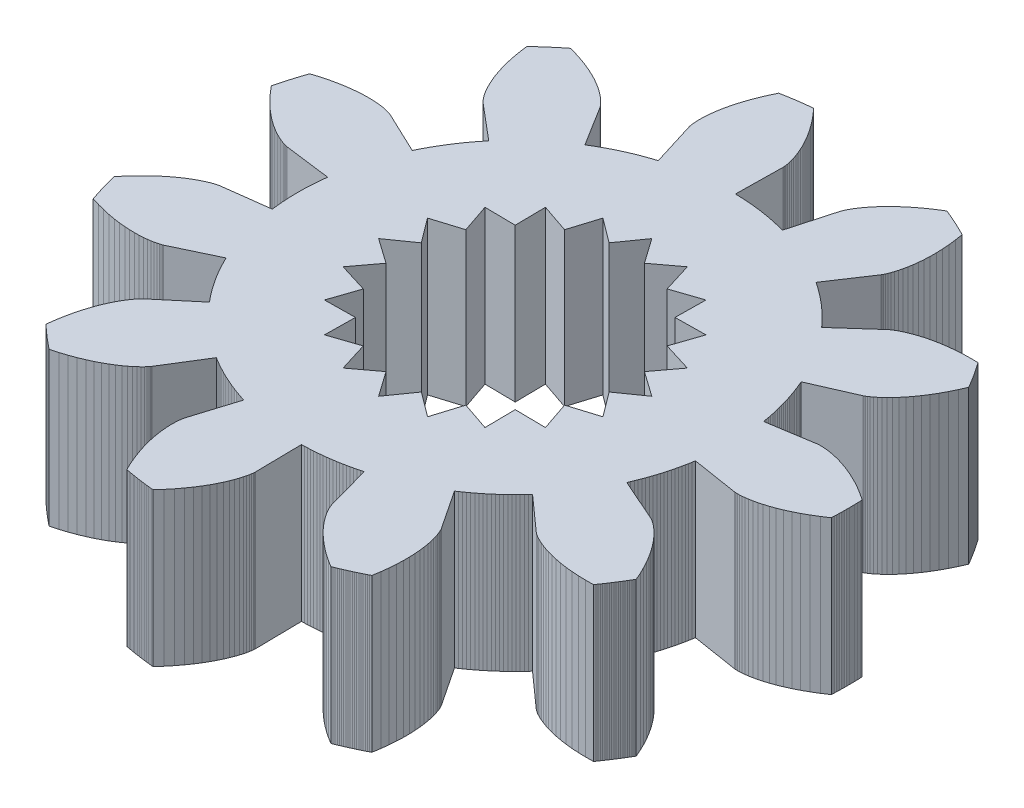
from build123d import *

# Parameters (mm, degrees)
BOSS_EXTRUDE1_DEPTH = 3
CUT_EXTRUDE1_DEPTH  = 4


with BuildPart() as part:
    # Sketch2 → Boss-Extrude1 (new body)
    with BuildSketch(Plane(origin=(0, 0, 0), x_dir=(1, 0, 0), z_dir=(0, 1, 0))):
        Polygon((4.197259488, -0.667467448), (5.104173112, -0.81168901), (5.108301421, -0.812232692), (5.120736405, -0.813420847), (5.14152309, -0.814586326), (5.170666294, -0.815059939), (5.208130563, -0.814172611), (5.253840203, -0.811257536), (5.307679433, -0.805652332), (5.369492635, -0.796701175), (5.439084718, -0.783756935), (5.516221584, -0.76618328), (5.600630705, -0.74335676), (5.692001799, -0.714668865), (5.789987608, -0.679528041), (5.894204785, -0.637361675), (6.004234873, -0.587618026), (6.119625381, -0.529768117), (6.239890958, -0.463307569), (6.364514658, -0.38775837), (6.492949292, -0.302670597), (6.494355324, -0.270830071), (6.495605215, -0.238983033), (6.496698936, -0.207130249), (6.497636459, -0.175272485), (6.498417763, -0.143410507), (6.499042829, -0.111545081), (6.499511642, -0.079676974), (6.49982419, -0.04780695), (6.499980465, -0.015935778), (6.499980465, 0.015935778), (6.49982419, 0.04780695), (6.499511642, 0.079676974), (6.499042829, 0.111545081), (6.498417763, 0.143410507), (6.497636459, 0.175272485), (6.496698936, 0.207130249), (6.495605215, 0.238983033), (6.494355324, 0.270830071), (6.492949292, 0.302670597), (6.364514658, 0.38775837), (6.239890958, 0.463307569), (6.119625381, 0.529768117), (6.004234873, 0.587618026), (5.894204785, 0.637361675), (5.789987608, 0.679528041), (5.692001799, 0.714668865), (5.600630705, 0.74335676), (5.516221584, 0.76618328), (5.439084718, 0.783756935), (5.369492635, 0.796701175), (5.307679433, 0.805652332), (5.253840203, 0.811257536), (5.208130563, 0.814172611), (5.170666294, 0.815059939), (5.14152309, 0.814586326), (5.120736405, 0.813420847), (5.108301421, 0.812232692), (5.104173112, 0.81168901), (4.197259488, 0.667467448), (4.187893514, 0.723911537), (4.177768525, 0.780224425), (4.166886354, 0.836395905), (4.155248975, 0.892415795), (4.142858497, 0.948273944), (4.129717165, 1.003960227), (4.115827361, 1.059464552), (4.101191602, 1.114776859), (4.085812541, 1.169887123), (4.069692965, 1.224785357), (4.052835796, 1.279461609), (4.035244089, 1.333905971), (4.016921033, 1.388108576), (3.997869947, 1.442059599), (3.978094286, 1.495749262), (3.957597632, 1.549167835), (3.936383702, 1.602305636), (3.914456339, 1.655153035), (3.891819519, 1.707700452), (4.732735872, 2.076688076), (4.736502764, 2.078462635), (4.747606104, 2.084185955), (4.765723081, 2.094443622), (4.790495959, 2.109801199), (4.821533181, 2.13080238), (4.858410569, 2.157967194), (4.900672609, 2.191790277), (4.947833823, 2.232739209), (4.999380224, 2.281252917), (5.05477085, 2.337740156), (5.113439373, 2.402578062), (5.174795781, 2.476110798), (5.238228126, 2.558648268), (5.303104336, 2.650464933), (5.368774089, 2.75179871), (5.434570739, 2.862849968), (5.499813295, 2.98378062), (5.563808443, 3.114713309), (5.62585261, 3.255730704), (5.60982115, 3.283276817), (5.593654817, 3.310743993), (5.577353998, 3.33813157), (5.560919086, 3.36543889), (5.544350475, 3.392665296), (5.527648564, 3.419810134), (5.510813754, 3.446872751), (5.493846451, 3.473852497), (5.476747062, 3.500748723), (5.459515998, 3.527560782), (5.442153673, 3.554288029), (5.424660506, 3.580929823), (5.407036916, 3.607485522), (5.389283327, 3.633954487), (5.371400167, 3.660336084), (5.353387864, 3.686629677), (5.335246853, 3.712834634), (5.316977569, 3.738950325), (5.298580451, 3.764976122), (5.144532438, 3.767119506), (4.99884733, 3.763298877), (4.861742203, 3.754188569), (4.733393509, 3.74047019), (4.613936862, 3.722830454), (4.503466934, 3.701958999), (4.402037463, 3.678546213), (4.309661361, 3.653281063), (4.226310941, 3.626848937), (4.151918244, 3.599929498), (4.086375474, 3.573194565), (4.029535539, 3.547306018), (3.981212694, 3.522913731), (3.941183289, 3.50065355), (3.909186616, 3.481145305), (3.884925846, 3.464990871), (3.86806908, 3.452772278), (3.858250471, 3.445049877), (3.855071452, 3.442360571), (3.170099226, 2.830719149), (3.131704089, 2.873139311), (3.09274136, 2.915038744), (3.053218101, 2.956409855), (3.013141475, 2.997245143), (2.972518746, 3.03753721), (2.931357277, 3.077278752), (2.889664526, 3.116462566), (2.847448051, 3.155081551), (2.804715504, 3.193128708), (2.761474628, 3.23059714), (2.717733261, 3.267480057), (2.673499331, 3.303770774), (2.628780855, 3.339462714), (2.583585936, 3.374549408), (2.537922768, 3.409024498), (2.491799625, 3.442881733), (2.445224867, 3.47611498), (2.398206935, 3.508718213), (2.350754351, 3.540685524), (2.858688433, 4.305731371), (2.860897945, 4.30926076), (2.867144409, 4.320078442), (2.876839667, 4.338502518), (2.889377004, 4.364815363), (2.904133082, 4.39926267), (2.920469908, 4.442052587), (2.937736859, 4.493354959), (2.955272732, 4.55330067), (2.972407833, 4.621981087), (2.988466086, 4.699447609), (3.00276717, 4.785711326), (3.014628667, 4.880742778), (3.023368225, 4.98447183), (3.028305729, 5.096787651), (3.028765465, 5.217538798), (3.024078287, 5.346533417), (3.013583771, 5.483539543), (2.996632359, 5.628285519), (2.972587474, 5.78046051), (2.944208399, 5.794966514), (2.915758538, 5.809333193), (2.887238574, 5.823560201), (2.858649194, 5.837647196), (2.829991085, 5.851593839), (2.801264936, 5.865399795), (2.772471438, 5.879064732), (2.743611282, 5.892588322), (2.714685163, 5.905970239), (2.685693776, 5.919210162), (2.656637818, 5.932307772), (2.627517989, 5.945262754), (2.598334987, 5.958074798), (2.569089514, 5.970743594), (2.539782274, 5.983268839), (2.510413971, 5.995650231), (2.480985312, 6.007887472), (2.451497004, 6.019980269), (2.421949755, 6.03192833), (2.291197519, 5.950446816), (2.170704995, 5.868469383), (2.060290228, 5.786680675), (1.959733151, 5.705749498), (1.868776585, 5.626326868), (1.787127329, 5.549044131), (1.714457336, 5.474511129), (1.650404984, 5.403314442), (1.594576436, 5.336015683), (1.546547064, 5.273149882), (1.505862973, 5.215223928), (1.472042582, 5.162715107), (1.444578285, 5.116069707), (1.422938169, 5.075701721), (1.406567807, 5.041991634), (1.394892096, 5.015285297), (1.387317152, 4.995892906), (1.383232257, 4.984088069), (1.382011846, 4.980106973), (1.136454858, 4.095237521), (1.081220742, 4.110165654), (1.025790665, 4.124348859), (0.970174673, 4.137784565), (0.914382847, 4.150470336), (0.858425296, 4.162403874), (0.802312165, 4.173583016), (0.746053622, 4.184005735), (0.689659864, 4.193670143), (0.633141111, 4.202574489), (0.576507608, 4.210717157), (0.519769618, 4.218096673), (0.462937425, 4.224711699), (0.406021329, 4.230561036), (0.349031646, 4.235643624), (0.291978703, 4.239958542), (0.234872843, 4.243505007), (0.177724414, 4.246282378), (0.120543774, 4.24829015), (0.063341286, 4.24952796), (0.077027616, 5.167735379), (0.076978243, 5.171899042), (0.076384623, 5.184376549), (0.074579985, 5.20511752), (0.070901266, 5.23403149), (0.064691249, 5.270988146), (0.055300686, 5.31581767), (0.042090413, 5.36831119), (0.02443343, 5.428221341), (0.001716958, 5.495262919), (-0.026655544, 5.569113652), (-0.061262393, 5.649415057), (-0.102661749, 5.735773411), (-0.151389724, 5.827760806), (-0.207958549, 5.924916303), (-0.272854793, 6.026747184), (-0.346537655, 6.132730282), (-0.429437307, 6.242313407), (-0.521953325, 6.354916845), (-0.624453181, 6.469934947), (-0.656169717, 6.466795288), (-0.687870476, 6.463500152), (-0.719554697, 6.460049616), (-0.751221618, 6.456443764), (-0.782870478, 6.452682684), (-0.814500516, 6.448766464), (-0.846110971, 6.4446952), (-0.877701084, 6.44046899), (-0.909270094, 6.436087934), (-0.940817243, 6.431552139), (-0.972341773, 6.426861713), (-1.003842925, 6.422016769), (-1.035319942, 6.417017424), (-1.066772068, 6.411863797), (-1.098198546, 6.406556014), (-1.12959862, 6.4010942), (-1.160971536, 6.395478488), (-1.192316539, 6.389709013), (-1.223632876, 6.383785913), (-1.289576423, 6.244549306), (-1.346620838, 6.110442324), (-1.395289338, 5.981942554), (-1.436128636, 5.859493655), (-1.469707053, 5.743504256), (-1.496612576, 5.634346959), (-1.517450882, 5.532357443), (-1.532843313, 5.437833663), (-1.543424821, 5.351035152), (-1.549841881, 5.272182436), (-1.552750382, 5.201456543), (-1.552813493, 5.138998628), (-1.550699523, 5.0849097), (-1.547079766, 5.03925046), (-1.542626341, 5.002041244), (-1.538010039, 4.973262077), (-1.533898169, 4.952852836), (-1.530952425, 4.940713514), (-1.529826757, 4.936704599), (-1.258005897, 4.059546916), (-1.31254255, 4.042243443), (-1.366841318, 4.024207352), (-1.420892358, 4.005441912), (-1.474685875, 3.985950523), (-1.52821212, 3.965736718), (-1.58146139, 3.944804161), (-1.634424036, 3.923156646), (-1.687090458, 3.900798096), (-1.73945111, 3.877732564), (-1.791496504, 3.853964229), (-1.843217206, 3.8294974), (-1.894603842, 3.80433651), (-1.945647099, 3.778486121), (-1.996337726, 3.751950917), (-2.046666536, 3.724735707), (-2.096624407, 3.696845425), (-2.146202285, 3.668285124), (-2.195391184, 3.639059982), (-2.244182189, 3.609175294), (-2.729088926, 4.389019917), (-2.731381507, 4.392495921), (-2.738626742, 4.402671732), (-2.751358315, 4.419144486), (-2.770085123, 4.441479601), (-2.795289599, 4.469212129), (-2.827426113, 4.501848203), (-2.866919442, 4.538866549), (-2.914163314, 4.579720089), (-2.96951904, 4.623837602), (-3.033314228, 4.670625459), (-3.105841579, 4.719469425), (-3.187357785, 4.769736514), (-3.278082506, 4.820776902), (-3.378197457, 4.871925892), (-3.487845583, 4.922505921), (-3.607130339, 4.971828615), (-3.736115075, 5.01919687), (-3.874822517, 5.063906975), (-4.023234364, 5.105250753), (-4.048218583, 5.085462251), (-4.073105473, 5.065551481), (-4.097894436, 5.045518922), (-4.122584875, 5.025365056), (-4.147176196, 5.005090368), (-4.171667809, 4.984695346), (-4.196059125, 4.964180478), (-4.220349557, 4.943546259), (-4.244538521, 4.922793185), (-4.268625436, 4.901921755), (-4.292609722, 4.88093247), (-4.316490803, 4.859825835), (-4.340268105, 4.838602358), (-4.363941056, 4.817262549), (-4.387509086, 4.79580692), (-4.41097163, 4.774235989), (-4.434328124, 4.752550272), (-4.457578005, 4.730750293), (-4.480720714, 4.708836574), (-4.460918963, 4.556051513), (-4.43640407, 4.412393001), (-4.407874398, 4.277979939), (-4.376029729, 4.152889978), (-4.341569086, 4.037159623), (-4.305188562, 3.930784438), (-4.267579166, 3.833719359), (-4.229424689, 3.745879118), (-4.191399603, 3.667138769), (-4.15416698, 3.597334318), (-4.118376462, 3.536263457), (-4.084662256, 3.483686395), (-4.053641189, 3.439326791), (-4.025910807, 3.402872783), (-4.002047526, 3.373978101), (-3.982604854, 3.352263287), (-3.96811166, 3.337316986), (-3.959070529, 3.328697328), (-3.955956174, 3.325933396), (-3.253058668, 2.734978849), (-3.289582857, 2.6909375), (-3.32551084, 2.646408445), (-3.360836105, 2.601399753), (-3.395552251, 2.555919582), (-3.429652986, 2.509976175), (-3.463132128, 2.463577858), (-3.495983611, 2.416733042), (-3.528201479, 2.369450215), (-3.559779895, 2.321737948), (-3.590713134, 2.273604889), (-3.620995591, 2.225059759), (-3.650621776, 2.176111359), (-3.679586321, 2.12676856), (-3.707883976, 2.077040303), (-3.735509612, 2.026935603), (-3.762458222, 1.97646354), (-3.788724923, 1.925633262), (-3.814304953, 1.874453981), (-3.839193676, 1.822934973), (-4.668739016, 2.216821643), (-4.672546928, 2.218506381), (-4.684143466, 2.223149748), (-4.70375979, 2.230124303), (-4.731589058, 2.23878932), (-4.767785749, 2.248492839), (-4.812465099, 2.258573739), (-4.865702631, 2.268363849), (-4.927533796, 2.277190068), (-4.997953724, 2.284376516), (-5.076917076, 2.289246684), (-5.164338009, 2.291125597), (-5.260090245, 2.289341975), (-5.364007254, 2.283230394), (-5.475882542, 2.272133433), (-5.595470044, 2.25540381), (-5.722484628, 2.232406492), (-5.856602704, 2.202520791), (-5.997462938, 2.165142419), (-6.144667063, 2.119685517), (-6.154986653, 2.08953088), (-6.165158262, 2.059326006), (-6.175181646, 2.02907162), (-6.185056562, 1.998768451), (-6.194782775, 1.968417226), (-6.204360049, 1.938018675), (-6.213788155, 1.907573529), (-6.223066865, 1.877082521), (-6.232195958, 1.846546383), (-6.241175213, 1.815965849), (-6.250004414, 1.785341655), (-6.25868335, 1.754674537), (-6.267211811, 1.723965232), (-6.275589592, 1.693214478), (-6.283816493, 1.662423015), (-6.291892315, 1.631591584), (-6.299816864, 1.600720925), (-6.30758995, 1.569811781), (-6.315211385, 1.538864894), (-6.215951252, 1.421039556), (-6.117660356, 1.313440077), (-6.02099048, 1.215788919), (-5.926572302, 1.127773076), (-5.835013611, 1.049045336), (-5.746897599, 0.979225632), (-5.662781218, 0.917902466), (-5.58319361, 0.864634421), (-5.508634625, 0.818951738), (-5.439573415, 0.780357972), (-5.376447114, 0.748331709), (-5.319659613, 0.722328346), (-5.269580419, 0.701781928), (-5.226543612, 0.686107041), (-5.190846899, 0.674700751), (-5.162750767, 0.66694459), (-5.142477736, 0.662206573), (-5.130211714, 0.65984326), (-5.126097457, 0.659201839), (-4.215288297, 0.542074321), (-4.222203849, 0.485277914), (-4.228354167, 0.428393554), (-4.233738136, 0.371431553), (-4.238354779, 0.314402233), (-4.242203262, 0.257315931), (-4.245282885, 0.200182992), (-4.24759309, 0.143013772), (-4.24913346, 0.085818633), (-4.249903715, 0.028607939), (-4.249903715, -0.028607939), (-4.24913346, -0.085818633), (-4.24759309, -0.143013772), (-4.245282885, -0.200182992), (-4.242203262, -0.257315931), (-4.238354779, -0.314402233), (-4.233738136, -0.371431553), (-4.228354167, -0.428393554), (-4.222203849, -0.485277914), (-4.215288297, -0.542074321), (-5.126097457, -0.659201839), (-5.130211714, -0.65984326), (-5.142477736, -0.662206573), (-5.162750767, -0.66694459), (-5.190846899, -0.674700751), (-5.226543612, -0.686107041), (-5.269580419, -0.701781928), (-5.319659613, -0.722328346), (-5.376447114, -0.748331709), (-5.439573415, -0.780357972), (-5.508634625, -0.818951738), (-5.58319361, -0.864634421), (-5.662781218, -0.917902466), (-5.746897599, -0.979225632), (-5.835013611, -1.049045336), (-5.926572302, -1.127773076), (-6.02099048, -1.215788919), (-6.117660356, -1.313440077), (-6.215951252, -1.421039556), (-6.315211385, -1.538864894), (-6.30758995, -1.569811781), (-6.299816864, -1.600720925), (-6.291892315, -1.631591584), (-6.283816493, -1.662423015), (-6.275589592, -1.693214478), (-6.267211811, -1.723965232), (-6.25868335, -1.754674537), (-6.250004414, -1.785341655), (-6.241175213, -1.815965849), (-6.232195958, -1.846546383), (-6.223066865, -1.877082521), (-6.213788155, -1.907573529), (-6.204360049, -1.938018675), (-6.194782775, -1.968417226), (-6.185056562, -1.998768451), (-6.175181646, -2.02907162), (-6.165158262, -2.059326006), (-6.154986653, -2.08953088), (-6.144667063, -2.119685517), (-5.997462938, -2.165142419), (-5.856602704, -2.202520791), (-5.722484628, -2.232406492), (-5.595470044, -2.25540381), (-5.475882542, -2.272133433), (-5.364007254, -2.283230394), (-5.260090245, -2.289341975), (-5.164338009, -2.291125597), (-5.076917076, -2.289246684), (-4.997953724, -2.284376516), (-4.927533796, -2.277190068), (-4.865702631, -2.268363849), (-4.812465099, -2.258573739), (-4.767785749, -2.248492839), (-4.731589058, -2.23878932), (-4.70375979, -2.230124303), (-4.684143466, -2.223149748), (-4.672546928, -2.218506381), (-4.668739016, -2.216821643), (-3.839193676, -1.822934973), (-3.814304953, -1.874453981), (-3.788724923, -1.925633262), (-3.762458222, -1.97646354), (-3.735509612, -2.026935603), (-3.707883976, -2.077040303), (-3.679586321, -2.12676856), (-3.650621776, -2.176111359), (-3.620995591, -2.225059759), (-3.590713134, -2.273604889), (-3.559779895, -2.321737948), (-3.528201479, -2.369450215), (-3.495983611, -2.416733042), (-3.463132128, -2.463577858), (-3.429652986, -2.509976175), (-3.395552251, -2.555919582), (-3.360836105, -2.601399753), (-3.32551084, -2.646408445), (-3.289582857, -2.6909375), (-3.253058668, -2.734978849), (-3.955956174, -3.325933396), (-3.959070529, -3.328697328), (-3.96811166, -3.337316986), (-3.982604854, -3.352263287), (-4.002047526, -3.373978101), (-4.025910807, -3.402872783), (-4.053641189, -3.439326791), (-4.084662256, -3.483686395), (-4.118376462, -3.536263457), (-4.15416698, -3.597334318), (-4.191399603, -3.667138769), (-4.229424689, -3.745879118), (-4.267579166, -3.833719359), (-4.305188562, -3.930784438), (-4.341569086, -4.037159623), (-4.376029729, -4.152889978), (-4.407874398, -4.277979939), (-4.43640407, -4.412393001), (-4.460918963, -4.556051513), (-4.480720714, -4.708836574), (-4.457578005, -4.730750293), (-4.434328124, -4.752550272), (-4.41097163, -4.774235989), (-4.387509086, -4.79580692), (-4.363941056, -4.817262549), (-4.340268105, -4.838602358), (-4.316490803, -4.859825835), (-4.292609722, -4.88093247), (-4.268625436, -4.901921755), (-4.244538521, -4.922793185), (-4.220349557, -4.943546259), (-4.196059125, -4.964180478), (-4.171667809, -4.984695346), (-4.147176196, -5.005090368), (-4.122584875, -5.025365056), (-4.097894436, -5.045518922), (-4.073105473, -5.065551481), (-4.048218583, -5.085462251), (-4.023234364, -5.105250753), (-3.874822517, -5.063906975), (-3.736115075, -5.01919687), (-3.607130339, -4.971828615), (-3.487845583, -4.922505921), (-3.378197457, -4.871925892), (-3.278082506, -4.820776902), (-3.187357785, -4.769736514), (-3.105841579, -4.719469425), (-3.033314228, -4.670625459), (-2.96951904, -4.623837602), (-2.914163314, -4.579720089), (-2.866919442, -4.538866549), (-2.827426113, -4.501848203), (-2.795289599, -4.469212129), (-2.770085123, -4.441479601), (-2.751358315, -4.419144486), (-2.738626742, -4.402671732), (-2.731381507, -4.392495921), (-2.729088926, -4.389019917), (-2.244182189, -3.609175294), (-2.195391184, -3.639059982), (-2.146202285, -3.668285124), (-2.096624407, -3.696845425), (-2.046666536, -3.724735707), (-1.996337726, -3.751950917), (-1.945647099, -3.778486121), (-1.894603842, -3.80433651), (-1.843217206, -3.8294974), (-1.791496504, -3.853964229), (-1.73945111, -3.877732564), (-1.687090458, -3.900798096), (-1.634424036, -3.923156646), (-1.58146139, -3.944804161), (-1.52821212, -3.965736718), (-1.474685875, -3.985950523), (-1.420892358, -4.005441912), (-1.366841318, -4.024207352), (-1.31254255, -4.042243443), (-1.258005897, -4.059546916), (-1.529826757, -4.936704599), (-1.530952425, -4.940713514), (-1.533898169, -4.952852836), (-1.538010039, -4.973262077), (-1.542626341, -5.002041244), (-1.547079766, -5.03925046), (-1.550699523, -5.0849097), (-1.552813493, -5.138998628), (-1.552750382, -5.201456543), (-1.549841881, -5.272182436), (-1.543424821, -5.351035152), (-1.532843313, -5.437833663), (-1.517450882, -5.532357443), (-1.496612576, -5.634346959), (-1.469707053, -5.743504256), (-1.436128636, -5.859493655), (-1.395289338, -5.981942554), (-1.346620838, -6.110442324), (-1.289576423, -6.244549306), (-1.223632876, -6.383785913), (-1.192316539, -6.389709013), (-1.160971536, -6.395478488), (-1.12959862, -6.4010942), (-1.098198546, -6.406556014), (-1.066772068, -6.411863797), (-1.035319942, -6.417017424), (-1.003842925, -6.422016769), (-0.972341773, -6.426861713), (-0.940817243, -6.431552139), (-0.909270094, -6.436087934), (-0.877701084, -6.44046899), (-0.846110971, -6.4446952), (-0.814500516, -6.448766464), (-0.782870478, -6.452682684), (-0.751221618, -6.456443764), (-0.719554697, -6.460049616), (-0.687870476, -6.463500152), (-0.656169717, -6.466795288), (-0.624453181, -6.469934947), (-0.521953325, -6.354916845), (-0.429437307, -6.242313407), (-0.346537655, -6.132730282), (-0.272854793, -6.026747184), (-0.207958549, -5.924916303), (-0.151389724, -5.827760806), (-0.102661749, -5.735773411), (-0.061262393, -5.649415057), (-0.026655544, -5.569113652), (0.001716958, -5.495262919), (0.02443343, -5.428221341), (0.042090413, -5.36831119), (0.055300686, -5.31581767), (0.064691249, -5.270988146), (0.070901266, -5.23403149), (0.074579985, -5.20511752), (0.076384623, -5.184376549), (0.076978243, -5.171899042), (0.077027616, -5.167735379), (0.063341286, -4.24952796), (0.120543774, -4.24829015), (0.177724414, -4.246282378), (0.234872843, -4.243505007), (0.291978703, -4.239958542), (0.349031646, -4.235643624), (0.406021329, -4.230561036), (0.462937425, -4.224711699), (0.519769618, -4.218096673), (0.576507608, -4.210717157), (0.633141111, -4.202574489), (0.689659864, -4.193670143), (0.746053622, -4.184005735), (0.802312165, -4.173583016), (0.858425296, -4.162403874), (0.914382847, -4.150470336), (0.970174673, -4.137784565), (1.025790665, -4.124348859), (1.081220742, -4.110165654), (1.136454858, -4.095237521), (1.382011846, -4.980106973), (1.383232257, -4.984088069), (1.387317152, -4.995892906), (1.394892096, -5.015285297), (1.406567807, -5.041991634), (1.422938169, -5.075701721), (1.444578285, -5.116069707), (1.472042582, -5.162715107), (1.505862973, -5.215223928), (1.546547064, -5.273149882), (1.594576436, -5.336015683), (1.650404984, -5.403314442), (1.714457336, -5.474511129), (1.787127329, -5.549044131), (1.868776585, -5.626326868), (1.959733151, -5.705749498), (2.060290228, -5.786680675), (2.170704995, -5.868469383), (2.291197519, -5.950446816), (2.421949755, -6.03192833), (2.451497004, -6.019980269), (2.480985312, -6.007887472), (2.510413971, -5.995650231), (2.539782274, -5.983268839), (2.569089514, -5.970743594), (2.598334987, -5.958074798), (2.627517989, -5.945262754), (2.656637818, -5.932307772), (2.685693776, -5.919210162), (2.714685163, -5.905970239), (2.743611282, -5.892588322), (2.772471438, -5.879064732), (2.801264936, -5.865399795), (2.829991085, -5.851593839), (2.858649194, -5.837647196), (2.887238574, -5.823560201), (2.915758538, -5.809333193), (2.944208399, -5.794966514), (2.972587474, -5.78046051), (2.996632359, -5.628285519), (3.013583771, -5.483539543), (3.024078287, -5.346533417), (3.028765465, -5.217538798), (3.028305729, -5.096787651), (3.023368225, -4.98447183), (3.014628667, -4.880742778), (3.00276717, -4.785711326), (2.988466086, -4.699447609), (2.972407833, -4.621981087), (2.955272732, -4.55330067), (2.937736859, -4.493354959), (2.920469908, -4.442052587), (2.904133082, -4.39926267), (2.889377004, -4.364815363), (2.876839667, -4.338502518), (2.867144409, -4.320078442), (2.860897945, -4.30926076), (2.858688433, -4.305731371), (2.350754351, -3.540685524), (2.398206935, -3.508718213), (2.445224867, -3.47611498), (2.491799625, -3.442881733), (2.537922768, -3.409024498), (2.583585936, -3.374549408), (2.628780855, -3.339462714), (2.673499331, -3.303770774), (2.717733261, -3.267480057), (2.761474628, -3.23059714), (2.804715504, -3.193128708), (2.847448051, -3.155081551), (2.889664526, -3.116462566), (2.931357277, -3.077278752), (2.972518746, -3.03753721), (3.013141475, -2.997245143), (3.053218101, -2.956409855), (3.09274136, -2.915038744), (3.131704089, -2.873139311), (3.170099226, -2.830719149), (3.855071452, -3.442360571), (3.858250471, -3.445049877), (3.86806908, -3.452772278), (3.884925846, -3.464990871), (3.909186616, -3.481145305), (3.941183289, -3.50065355), (3.981212694, -3.522913731), (4.029535539, -3.547306018), (4.086375474, -3.573194565), (4.151918244, -3.599929498), (4.226310941, -3.626848937), (4.309661361, -3.653281063), (4.402037463, -3.678546213), (4.503466934, -3.701958999), (4.613936862, -3.722830454), (4.733393509, -3.74047019), (4.861742203, -3.754188569), (4.99884733, -3.763298877), (5.144532438, -3.767119506), (5.298580451, -3.764976122), (5.316977569, -3.738950325), (5.335246853, -3.712834634), (5.353387864, -3.686629677), (5.371400167, -3.660336084), (5.389283327, -3.633954487), (5.407036916, -3.607485522), (5.424660506, -3.580929823), (5.442153673, -3.554288029), (5.459515998, -3.527560782), (5.476747062, -3.500748723), (5.493846451, -3.473852497), (5.510813754, -3.446872751), (5.527648564, -3.419810134), (5.544350475, -3.392665296), (5.560919086, -3.36543889), (5.577353998, -3.33813157), (5.593654817, -3.310743993), (5.60982115, -3.283276817), (5.62585261, -3.255730704), (5.563808443, -3.114713309), (5.499813295, -2.98378062), (5.434570739, -2.862849968), (5.368774089, -2.75179871), (5.303104336, -2.650464933), (5.238228126, -2.558648268), (5.174795781, -2.476110798), (5.113439373, -2.402578062), (5.05477085, -2.337740156), (4.999380224, -2.281252917), (4.947833823, -2.232739209), (4.900672609, -2.191790277), (4.858410569, -2.157967194), (4.821533181, -2.13080238), (4.790495959, -2.109801199), (4.765723081, -2.094443622), (4.747606104, -2.084185955), (4.736502764, -2.078462635), (4.732735872, -2.076688076), (3.891819519, -1.707700452), (3.914456339, -1.655153035), (3.936383702, -1.602305636), (3.957597632, -1.549167835), (3.978094286, -1.495749262), (3.997869947, -1.442059599), (4.016921033, -1.388108576), (4.035244089, -1.333905971), (4.052835796, -1.279461609), (4.069692965, -1.224785357), (4.085812541, -1.169887123), (4.101191602, -1.114776859), (4.115827361, -1.059464552), (4.129717165, -1.003960227), (4.142858497, -0.948273944), (4.155248975, -0.892415795), (4.166886354, -0.836395905), (4.177768525, -0.780224425), (4.187893514, -0.723911537), align=None)
    extrude(amount=BOSS_EXTRUDE1_DEPTH)

    # Sketch3 → Cut-Extrude1 (cut, through all)
    with BuildSketch(Plane(origin=(0, 3, 0), x_dir=(1, 0, 0), z_dir=(0, 1, 0))):
        Polygon((-0.34604534, 2.184844287), (0, 2.675), (0.34604534, 2.184844287), (0.82662046, 2.544076181), (1.00426269, 1.970976506), (1.57232555, 2.16412046), (1.564175811, 1.564175811), (2.16412046, 1.57232555), (1.970976506, 1.00426269), (2.544076181, 0.82662046), (2.184844287, 0.34604534), (2.675, 0), (2.184844287, -0.34604534), (2.544076181, -0.82662046), (1.970976506, -1.00426269), (2.16412046, -1.57232555), (1.564175811, -1.564175811), (1.57232555, -2.16412046), (1.00426269, -1.970976506), (0.82662046, -2.544076181), (0.34604534, -2.184844287), (0, -2.675), (-0.34604534, -2.184844287), (-0.82662046, -2.544076181), (-1.00426269, -1.970976506), (-1.57232555, -2.16412046), (-1.564175811, -1.564175811), (-2.16412046, -1.57232555), (-1.970976506, -1.00426269), (-2.544076181, -0.82662046), (-2.184844287, -0.34604534), (-2.675, 0), (-2.184844287, 0.34604534), (-2.544076181, 0.82662046), (-1.970976506, 1.00426269), (-2.16412046, 1.57232555), (-1.564175811, 1.564175811), (-1.57232555, 2.16412046), (-1.00426269, 1.970976506), (-0.82662046, 2.544076181), align=None)
    extrude(amount=-CUT_EXTRUDE1_DEPTH, mode=Mode.SUBTRACT)


solid = part.part
